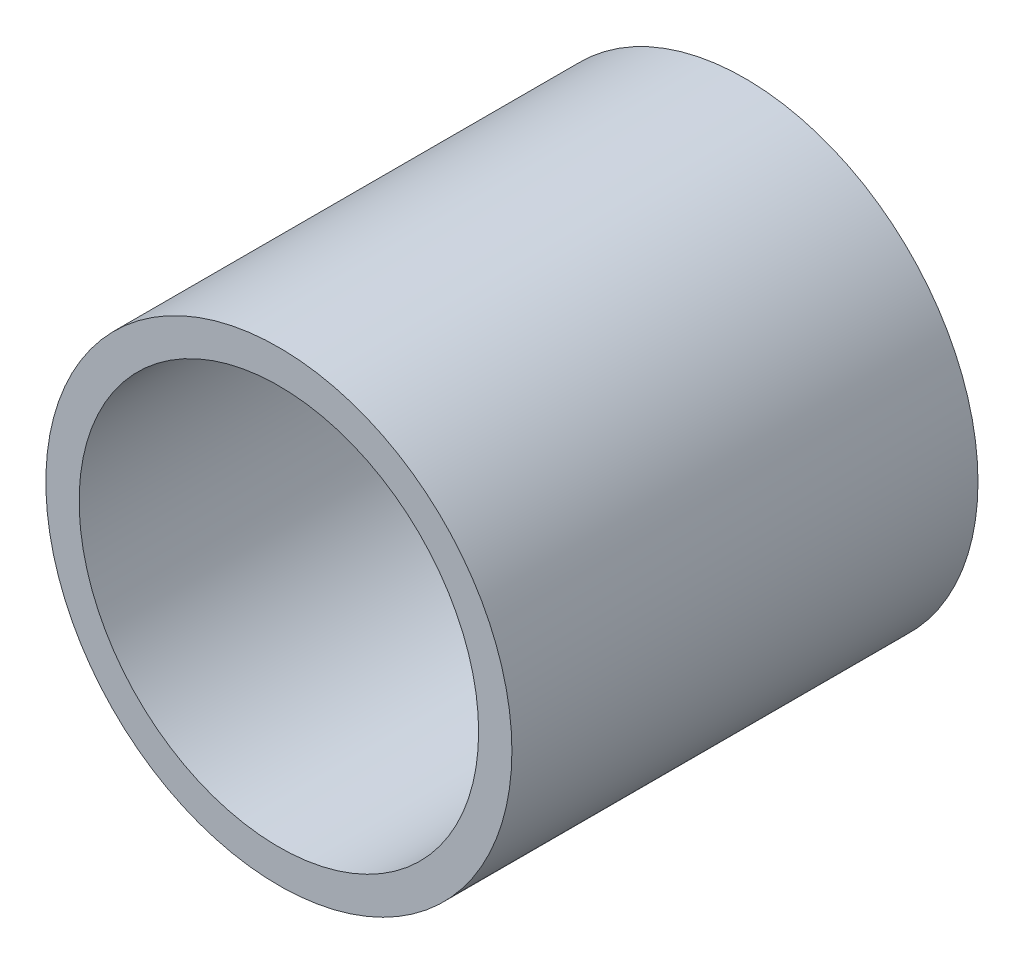
from build123d import *

# Parameters (mm, degrees)
SKETCH1_R           = 7
SKETCH1_R_2         = 6
BOSS_EXTRUDE1_DEPTH = 14


with BuildPart() as part:
    # Sketch1 → Boss-Extrude1 (new body)
    with BuildSketch(Plane.XY):
        Circle(SKETCH1_R)
        Circle(SKETCH1_R_2, mode=Mode.SUBTRACT)
    extrude(amount=BOSS_EXTRUDE1_DEPTH)


solid = part.part
